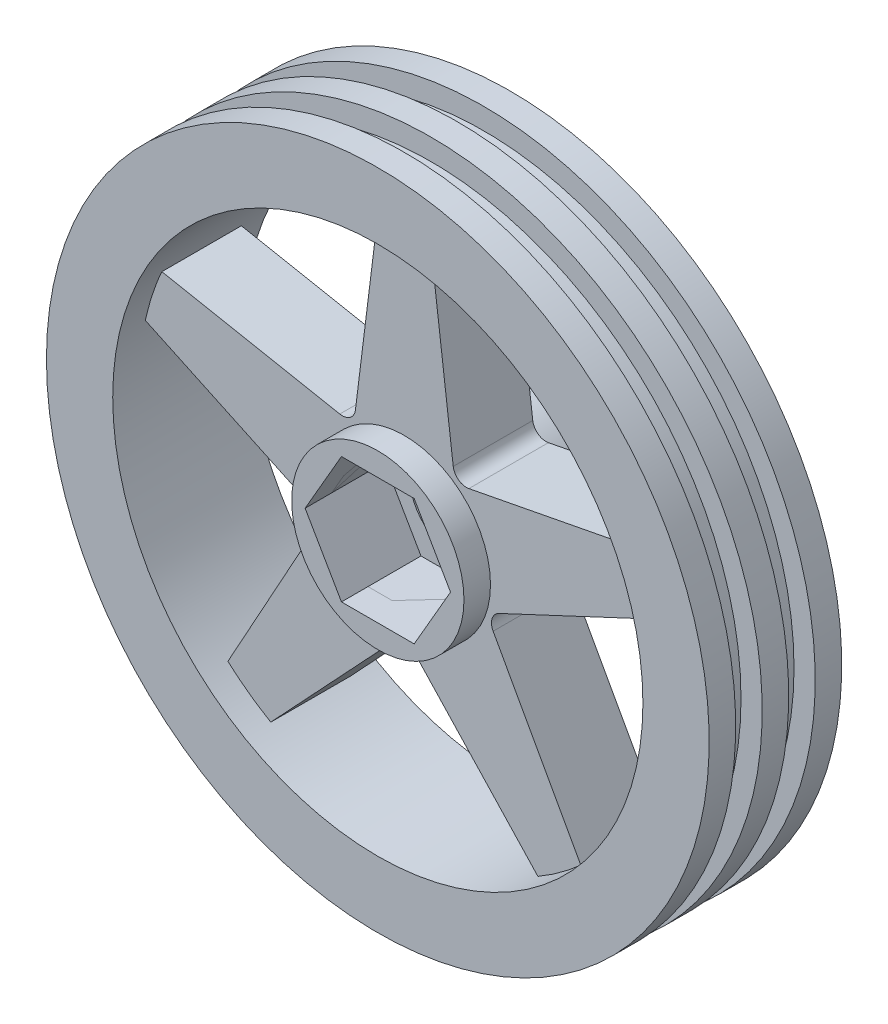
from build123d import *

# Parameters (mm, degrees)
SKETCH2_R           = 8.255
BOSS_EXTRUDE1_DEPTH = 6.35
BOSS_EXTRUDE3_DEPTH = 3.81
CUT_EXTRUDE1_DEPTH  = 7.62
SKETCH5_R           = 4.572
CUT_EXTRUDE2_DEPTH  = 6.08


with BuildPart() as part:
    # Sketch1 → Revolve1 (revolve)
    with BuildSketch(Plane(origin=(0, 0, 0), x_dir=(1, 0, 0), z_dir=(0, 1, 0))):
        Polygon((-25.4, 6.35), (-31.75, 6.35), (-31.75, 3.81), (-29.718, 3.81), (-29.718, 1.27), (-31.75, 1.27), (-31.75, -1.27), (-29.718, -1.27), (-29.718, -3.81), (-31.75, -3.81), (-31.75, -6.35), (-25.4, -6.35), align=None)
    revolve(axis=Axis((0, 0, -7.15010339), (0, 0, 1)))


with BuildPart() as body_2:
    # Sketch2 → Boss-Extrude1 (new body, symmetric)
    with BuildSketch(Plane.XY):
        Circle(SKETCH2_R)
    extrude(amount=BOSS_EXTRUDE1_DEPTH, both=True)


with BuildPart() as body_3:
    # Sketch3 → Boss-Extrude3 (new body, symmetric)
    with BuildSketch(Plane.XY):
        with BuildLine():
            Line((-4.684628445, 8.025767673), (-2.54, 25.272680903))
            ThreePointArc((-2.54, 25.272680903), (0, 25.4), (2.54, 25.272680903))
            Line((2.54, 25.272680903), (4.684628445, 8.025767673))
            ThreePointArc((4.684628445, 8.025767673), (5.198434869, 7.155031769), (6.185328842, 6.935445013))
            Line((6.185328842, 6.935445013), (23.250844691, 10.225371444))
            ThreePointArc((23.250844691, 10.225371444), (24.156835514, 7.849031657), (24.820651022, 5.394004341))
            Line((24.820651022, 5.394004341), (9.080588446, -1.975247805))
            ThreePointArc((9.080588446, -1.975247805), (8.411244307, -2.732978945), (8.507371901, -3.739426928))
            Line((8.507371901, -3.739426928), (16.909812286, -18.953053803))
            ThreePointArc((16.909812286, -18.953053803), (14.929745408, -20.549031657), (12.800005955, -21.939002884))
            Line((12.800005955, -21.939002884), (0.927483852, -9.246537953))
            ThreePointArc((0.927483852, -9.246537953), (0, -8.844105648), (-0.927483852, -9.246537953))
            Line((-0.927483852, -9.246537953), (-12.800005955, -21.939002884))
            ThreePointArc((-12.800005955, -21.939002884), (-14.929745408, -20.549031657), (-16.909812286, -18.953053803))
            Line((-16.909812286, -18.953053803), (-8.507371901, -3.739426928))
            ThreePointArc((-8.507371901, -3.739426928), (-8.411244307, -2.732978945), (-9.080588446, -1.975247805))
            Line((-9.080588446, -1.975247805), (-24.820651022, 5.394004341))
            ThreePointArc((-24.820651022, 5.394004341), (-24.156835514, 7.849031657), (-23.250844691, 10.225371444))
            Line((-23.250844691, 10.225371444), (-6.185328842, 6.935445013))
            ThreePointArc((-6.185328842, 6.935445013), (-5.198434869, 7.155031769), (-4.684628445, 8.025767673))
        make_face()
    extrude(amount=BOSS_EXTRUDE3_DEPTH, both=True)


with BuildPart() as cut_extrude1_tool:
    # Sketch4 → Cut-Extrude1 (new body)
    with BuildSketch(Plane.XY.offset(6.35)):
        Polygon((3.482865499, 6.0325), (-3.482865499, 6.0325), (-6.965730998, 0), (-3.482865499, -6.0325), (3.482865499, -6.0325), (6.965730998, 0), align=None)
    extrude(amount=-CUT_EXTRUDE1_DEPTH)


with BuildPart() as body_2_1:
    add(body_2.part)

    # Cut-Extrude1: cut by cut_extrude1_tool
    add(cut_extrude1_tool.part, mode=Mode.SUBTRACT)


with BuildPart() as body_3_1:
    add(body_3.part)

    # Cut-Extrude1: cut by cut_extrude1_tool
    add(cut_extrude1_tool.part, mode=Mode.SUBTRACT)


with BuildPart() as cut_extrude2_tool:
    # Sketch5 → Cut-Extrude2 (new body, through all)
    with BuildSketch(Plane.XY.offset(-1.27)):
        Circle(SKETCH5_R)
    extrude(amount=-CUT_EXTRUDE2_DEPTH)


with BuildPart() as body_2_2:
    add(body_2_1.part)

    # Cut-Extrude2: cut by cut_extrude2_tool
    add(cut_extrude2_tool.part, mode=Mode.SUBTRACT)


with BuildPart() as body_3_2:
    add(body_3_1.part)

    # Cut-Extrude2: cut by cut_extrude2_tool
    add(cut_extrude2_tool.part, mode=Mode.SUBTRACT)


solid = Compound([part.part, body_2_2.part, body_3_2.part])
